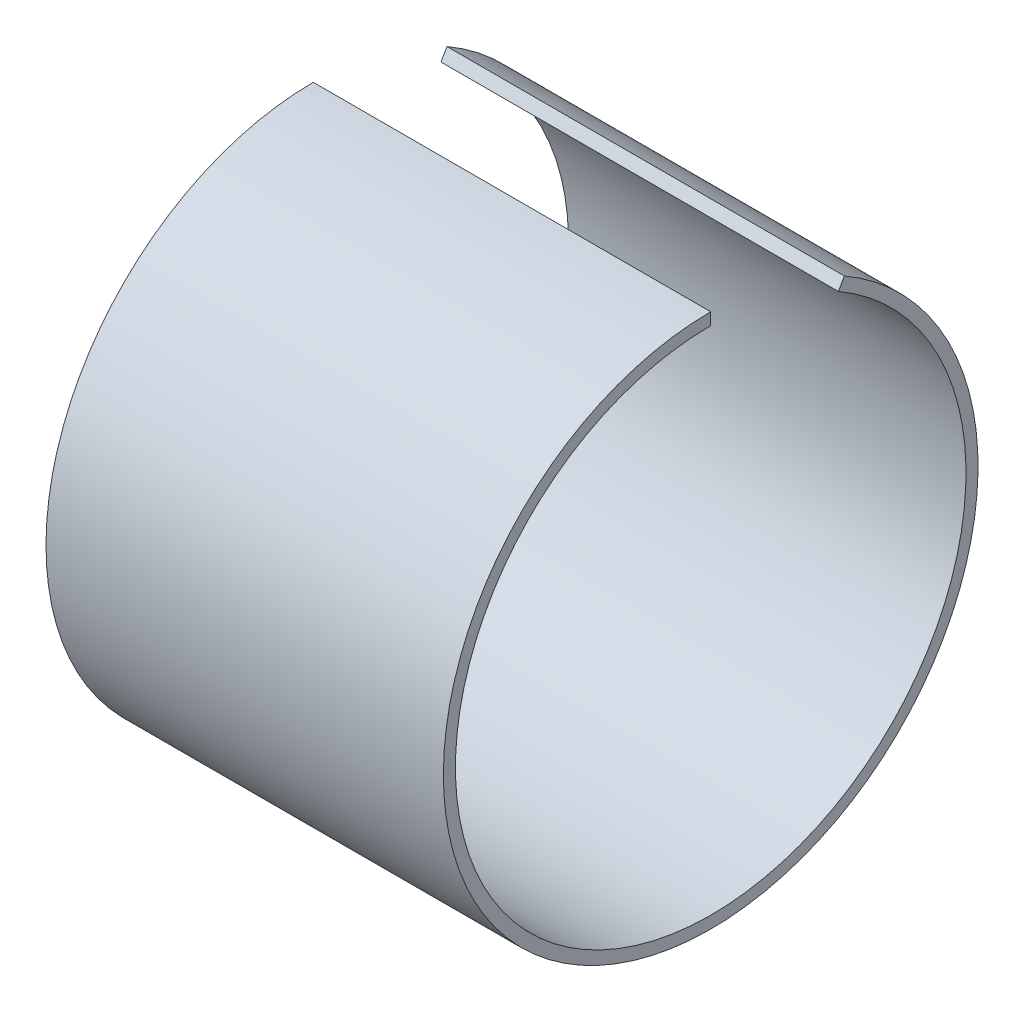
from build123d import *

# Parameters (mm, degrees)
SKETCH1_W      = 33
SKETCH1_H      = 1
REVOLVE1_ANGLE = 330


with BuildPart() as part:
    # Sketch1 → Revolve1 (revolve)
    with BuildSketch(Plane.XY):
        with Locations((16.5, 21.7)):
            Rectangle(SKETCH1_W, SKETCH1_H)
    revolve(axis=Axis((0, 0, 0), (1, 0, 0)), revolution_arc=REVOLVE1_ANGLE)


solid = part.part
